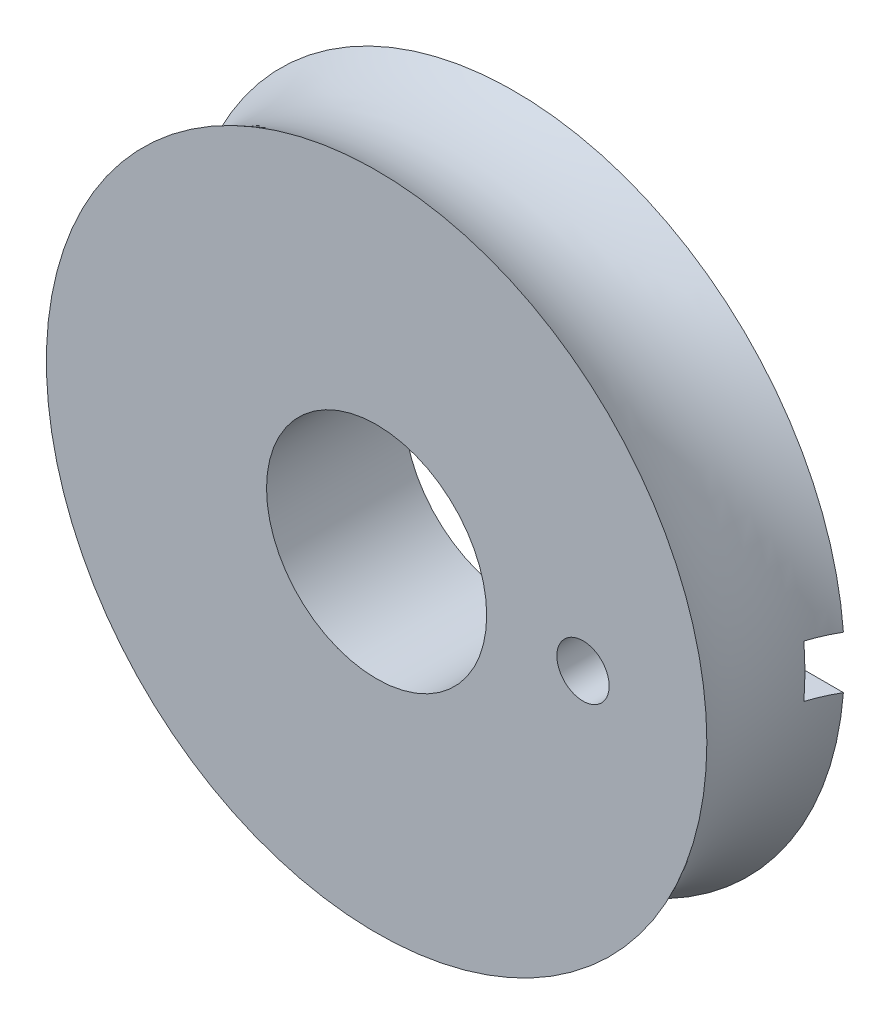
from build123d import *

# Parameters (mm, degrees)
ESQUISSE2_R             = 4
ENL_V_MAT_EXTRU_1_DEPTH = 10
ESQUISSE3_R             = 0.95
ENL_V_MAT_EXTRU_2_DEPTH = 5
ESQUISSE5_W             = 5
ESQUISSE5_H             = 1.9
ENL_V_MAT_EXTRU_4_DEPTH = 1


with BuildPart() as part:
    # Esquisse1 → Révolution1 (revolve)
    with BuildSketch(Plane(origin=(0, 0, 0), x_dir=(1, 0, 0), z_dir=(0, 1, 0))):
        with BuildLine():
            Line((0, 0), (0, 5))
            Line((0, 5), (12, 5))
            ThreePointArc((12, 5), (11.330127019, 2.5), (12, 0))
            Line((12, 0), (0, 0))
        make_face()
    revolve(axis=Axis((0, 0, 0), (0, 0, -1)))

    # Esquisse2 → Enlèv. mat.-Extru.1 (cut)
    with BuildSketch(Plane(origin=(0, 0, -5), x_dir=(-1, 0, 0), z_dir=(0, 0, -1))):
        Circle(ESQUISSE2_R)
    extrude(amount=-ENL_V_MAT_EXTRU_1_DEPTH, mode=Mode.SUBTRACT)

    # Esquisse3 → Enlèv. mat.-Extru.2 (cut)
    with BuildSketch(Plane(origin=(0, 0, -5), x_dir=(-1, 0, 0), z_dir=(0, 0, -1))):
        with Locations((-7.5, 0)):
            Circle(ESQUISSE3_R)
    extrude(amount=-ENL_V_MAT_EXTRU_2_DEPTH, mode=Mode.SUBTRACT)

    # Esquisse5 → Enlèv. mat.-Extru.4 (cut)
    with BuildSketch(Plane(origin=(0, 0, -5), x_dir=(-1, 0, 0), z_dir=(0, 0, -1))):
        with Locations((-10, 0)):
            Rectangle(ESQUISSE5_W, ESQUISSE5_H)
    extrude(amount=-ENL_V_MAT_EXTRU_4_DEPTH, mode=Mode.SUBTRACT)


solid = part.part
